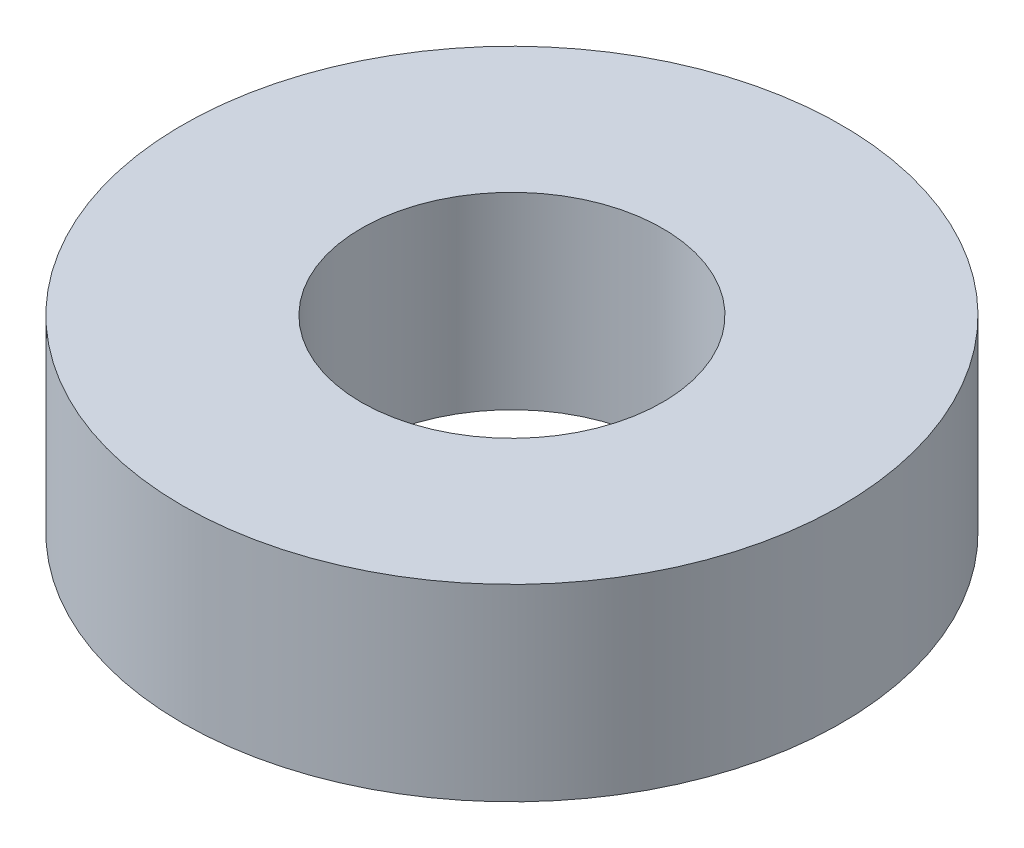
from build123d import *

# Parameters (mm, degrees)
SKETCH1_R           = 3.5
SKETCH1_R_2         = 1.6
BOSS_EXTRUDE1_DEPTH = 2


with BuildPart() as part:
    # Sketch1 → Boss-Extrude1 (new body)
    with BuildSketch(Plane(origin=(0, 0, 0), x_dir=(1, 0, 0), z_dir=(0, 1, 0))):
        Circle(SKETCH1_R)
        Circle(SKETCH1_R_2, mode=Mode.SUBTRACT)
    extrude(amount=BOSS_EXTRUDE1_DEPTH)


solid = part.part
